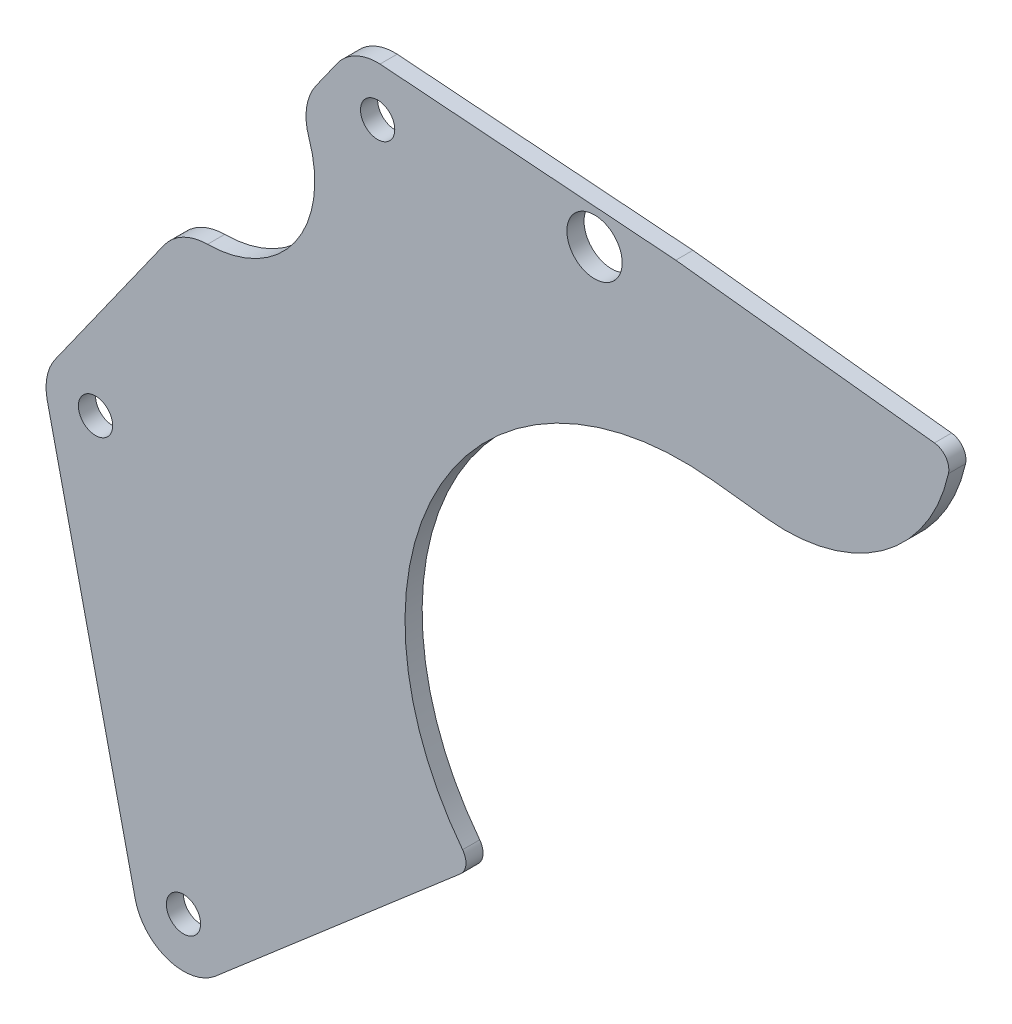
from build123d import *

# Parameters (mm, degrees)
SKETCH1_R           = 5.125
SKETCH1_R_2         = 3.175
BOSS_EXTRUDE1_DEPTH = 3.175
BOSS_EXTRUDE2_DEPTH = 3.175
FILLET1_R           = 3
FILLET2_R           = 3
SKETCH3_R           = 20
CUT_EXTRUDE1_DEPTH  = 10
FILLET3_R           = 10


with BuildPart() as part:
    # Sketch1 → Boss-Extrude1 (new body)
    with BuildSketch(Plane.XY):
        with BuildLine():
            Line((9.15916732, 81.880500013), (-1.226057593, 83.041443199))
            Line((-1.226057593, 83.041443199), (-56.039685464, 87.118947137))
            ThreePointArc((-56.039685464, 87.118947137), (-60.496641192, 86.206716079), (-63.967502721, 83.265672028))
            Line((-63.967502721, 83.265672028), (-116.255829355, 9.604754379))
            ThreePointArc((-116.255829355, 9.604754379), (-117.771483022, 6.090804864), (-117.721858217, 2.264241835))
            Line((-117.721858217, 2.264241835), (-101.423346554, -69.587878569))
            ThreePointArc((-101.423346554, -69.587878569), (-95.471980909, -76.230183562), (-86.689504727, -74.678706588))
            Line((-86.689504727, -74.678706588), (-38.949070428, -33.549176271))
            ThreePointArc((-38.949070428, -33.549176271), (-45.470819677, 24.007252392), (5.719870058, 51.114243705))
            Line((5.719870058, 51.114243705), (9.15916732, 81.880500013))
        make_face()
        with Locations((-16.285724201, 77.64676563)):
            Circle(SKETCH1_R, mode=Mode.SUBTRACT)
        with Locations((-56.48584008, 77.954801184)):
            Circle(SKETCH1_R_2, mode=Mode.SUBTRACT)
        with Locations((-108.774166869, 4.293883316)):
            Circle(SKETCH1_R_2, mode=Mode.SUBTRACT)
        with Locations((-92.47565523, -67.558236985)):
            Circle(SKETCH1_R_2, mode=Mode.SUBTRACT)
    extrude(amount=-BOSS_EXTRUDE1_DEPTH)

    # Sketch2 → Boss-Extrude2 (add)
    with BuildSketch(Plane.XY):
        with BuildLine():
            Line((9.15916732, 81.880500013), (5.719870058, 51.114243705))
            Line((5.719870058, 51.114243705), (15.657966891, 50.003284059))
            ThreePointArc((15.657966891, 50.003284059), (38.420342204, 56.582561483), (49.863520461, 77.330243105))
            Line((49.863520461, 77.330243105), (9.15916732, 81.880500013))
        make_face()
    extrude(amount=-BOSS_EXTRUDE2_DEPTH)

    # Fillet1
    fillet1_edges = [part.edges().sort_by_distance(p)[0] for p in [
        (49.863520461, 77.330243105, -1.5875),
    ]]
    fillet(fillet1_edges, radius=FILLET1_R)

    # Fillet2
    fillet2_edges = [part.edges().sort_by_distance(p)[0] for p in [
        (-38.949070428, -33.549176271, -1.5875),
    ]]
    fillet(fillet2_edges, radius=FILLET2_R)

    # Sketch3 → Cut-Extrude1 (cut)
    with BuildSketch(Plane(origin=(0, 0, -3.175), x_dir=(-1, 0, 0), z_dir=(0, 0, -1))):
        with Locations((88.139089591, 62.193219725)):
            Circle(SKETCH3_R)
    extrude(amount=-CUT_EXTRUDE1_DEPTH, mode=Mode.SUBTRACT)

    # Fillet3
    fillet3_edges = [part.edges().sort_by_distance(p)[0] for p in [
        (-71.283801873, 72.958872327, -1.5875),
        (-92.741786186, 42.730044649, -1.5875),
    ]]
    fillet(fillet3_edges, radius=FILLET3_R)


solid = part.part
